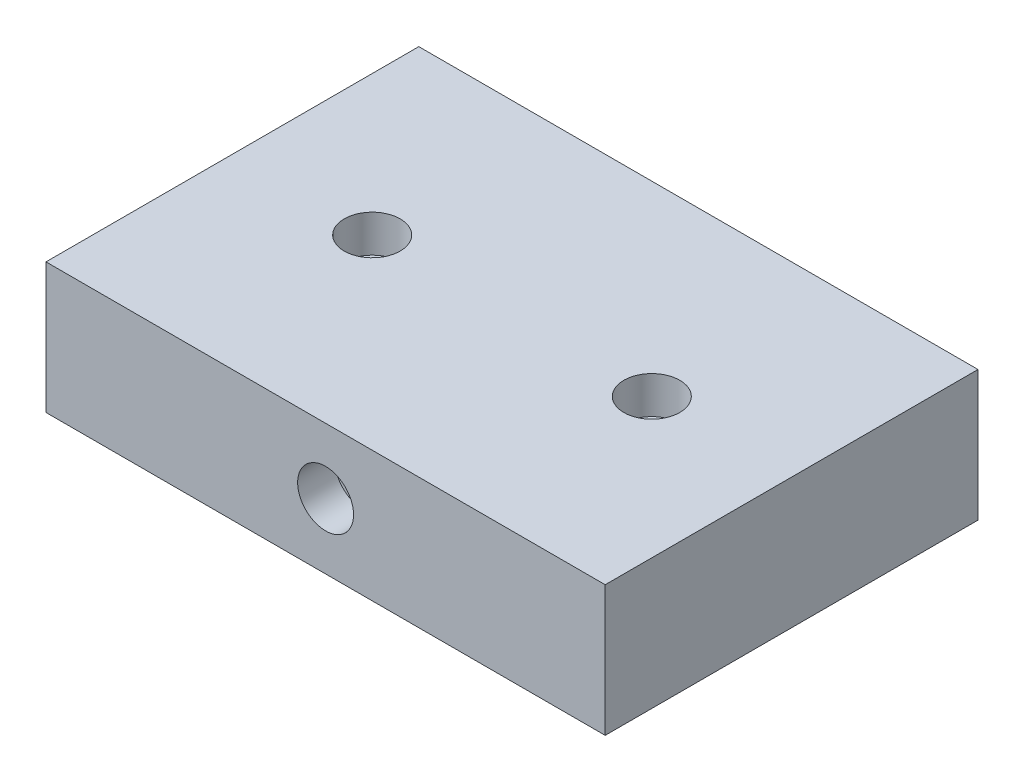
from build123d import *

# Parameters (mm, degrees)
SKETCH1_W           = 30
SKETCH1_H           = 7
BOSS_EXTRUDE1_DEPTH = 20
SKETCH2_R           = 1.5
CUT_EXTRUDE1_DEPTH  = 2
SKETCH3_R           = 1.5
CUT_EXTRUDE2_DEPTH  = 2


with BuildPart() as part:
    # Sketch1 → Boss-Extrude1 (new body)
    with BuildSketch(Plane.XY):
        with Locations((15, 3.5)):
            Rectangle(SKETCH1_W, SKETCH1_H)
    extrude(amount=BOSS_EXTRUDE1_DEPTH)

    # Sketch2 → Cut-Extrude1 (cut)
    with BuildSketch(Plane.XY.offset(20)):
        with Locations((15, 3.5)):
            Circle(SKETCH2_R)
    extrude(amount=-CUT_EXTRUDE1_DEPTH, mode=Mode.SUBTRACT)

    # Sketch3 → Cut-Extrude2 (cut)
    with BuildSketch(Plane(origin=(0, 7, 0), x_dir=(1, 0, 0), z_dir=(0, 1, 0))):
        with Locations((7.5, -10)):
            Circle(SKETCH3_R)
        with Locations((22.5, -10)):
            Circle(SKETCH3_R)
    extrude(amount=-CUT_EXTRUDE2_DEPTH, mode=Mode.SUBTRACT)


solid = part.part
